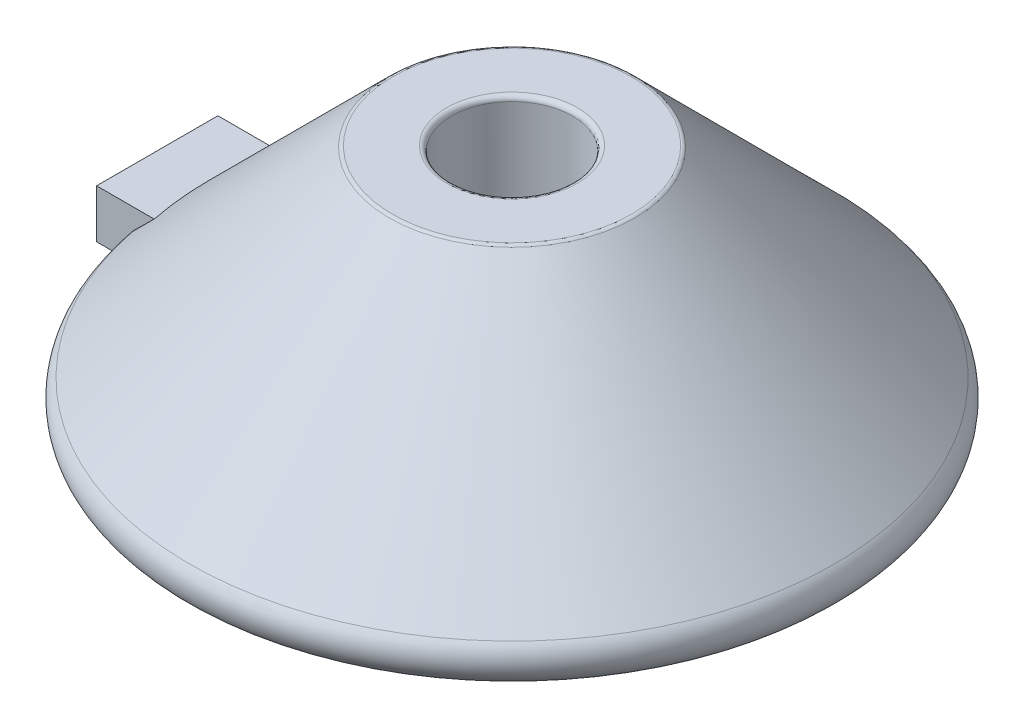
from build123d import *

# Parameters (mm, degrees)
FILLET1_R           = 2
FILLET2_R           = 10
SKETCH3_W           = 10
SKETCH3_H           = 20
BOSS_EXTRUDE1_DEPTH = 25
BOSS_EXTRUDE2_REACH = 322.147
SKETCH4_W           = 50
SKETCH4_H           = 20


with BuildPart() as part:
    # Sketch1 → Revolve1 (revolve)
    with BuildSketch(Plane.XY):
        Polygon((0, 0), (150, 0), (50, 100), (25, 100), (25, 50), (0, 50), align=None)
    revolve(axis=Axis((0, 50, 0), (0, -1, 0)))

    # Fillet1
    fillet1_edges = [part.edges().sort_by_distance(p)[0] for p in [
        (-25, 100, 0),
        (-50, 100, 0),
    ]]
    fillet(fillet1_edges, radius=FILLET1_R)

    # Fillet2
    fillet2_edges = [part.edges().sort_by_distance(p)[0] for p in [
        (-150, 0, 0),
    ]]
    fillet(fillet2_edges, radius=FILLET2_R)

    # Sketch4 → Boss-Extrude2 (add, up to next)
    with BuildSketch(Plane(origin=(-136.238585348, 0, 0), x_dir=(0, 0, -1), z_dir=(1, 0, 0)), mode=Mode.PRIVATE) as boss_extrude2_sk1:
        with Locations((0, 15)):
            Rectangle(SKETCH4_W, SKETCH4_H)
    boss_extrude2_tool1 = extrude(boss_extrude2_sk1.sketch, amount=BOSS_EXTRUDE2_REACH, mode=Mode.PRIVATE) - part.part


with BuildPart() as body_2:
    # Sketch3 → Boss-Extrude1 (new, symmetric)
    with BuildSketch(Plane.XY):
        with Locations((-141.238585348, 15)):
            Rectangle(SKETCH3_W, SKETCH3_H)
    extrude(amount=BOSS_EXTRUDE1_DEPTH, both=True)


with BuildPart() as part_1:
    add(part.part)

    add(body_2.part)  # Boss-Extrude2 merges body 2
    add(boss_extrude2_tool1.solids().sort_by_distance((-136.238585, 15, 0))[0])


solid = part_1.part
